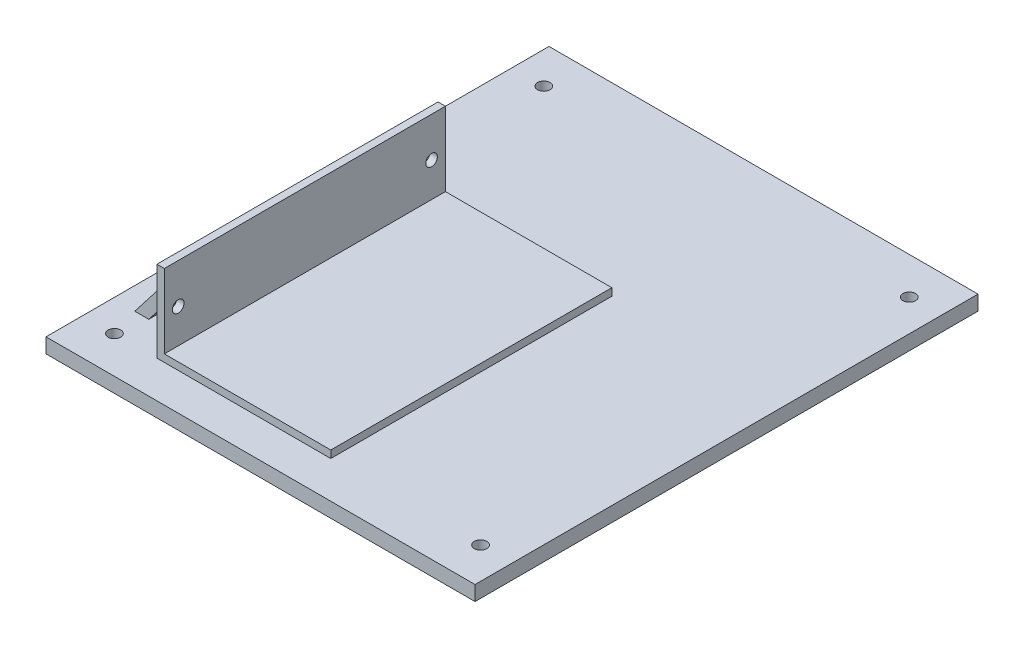
from build123d import *

# Parameters (mm, degrees)
SKETCH1_W           = 147.32
SKETCH1_H           = 5.08
BOSS_EXTRUDE1_DEPTH = 172.72
SKETCH2_R           = 2.159
CUT_EXTRUDE1_DEPTH  = 6.08
SKETCH3_W           = 59.69
SKETCH3_H           = 96.52
BOSS_EXTRUDE2_DEPTH = 2.54
SKETCH4_W           = 2.54
SKETCH4_H           = 96.52
BOSS_EXTRUDE3_DEPTH = 25.4
SKETCH5_W           = 76.2
SKETCH5_H           = 22.86
BOSS_EXTRUDE4_DEPTH = 17.78
CUT_EXTRUDE2_DEPTH  = 150.86
SKETCH7_R           = 2
CUT_EXTRUDE3_DEPTH  = 28.94


with BuildPart() as part:
    # Sketch1 → Boss-Extrude1 (new body)
    with BuildSketch(Plane.XY):
        Rectangle(SKETCH1_W, SKETCH1_H)
    extrude(amount=BOSS_EXTRUDE1_DEPTH)

    # Sketch2 → Cut-Extrude1 (cut, through all)
    with BuildSketch(Plane(origin=(0, 2.54, 0), x_dir=(1, 0, 0), z_dir=(0, 1, 0))):
        with Locations((62.738, -12.7)):
            Circle(SKETCH2_R)
        with Locations((-62.865, -160.02)):
            Circle(SKETCH2_R)
        with Locations((62.865, -160.02)):
            Circle(SKETCH2_R)
        with Locations((-62.738, -12.7)):
            Circle(SKETCH2_R)
    extrude(amount=-CUT_EXTRUDE1_DEPTH, mode=Mode.SUBTRACT)

    # Sketch3 → Boss-Extrude2 (add)
    with BuildSketch(Plane(origin=(0, 2.54, 0), x_dir=(1, 0, 0), z_dir=(0, 1, 0))):
        with Locations((-18.415, -111.76)):
            Rectangle(SKETCH3_W, SKETCH3_H)
    extrude(amount=BOSS_EXTRUDE2_DEPTH)

    # Sketch4 → Boss-Extrude3 (add)
    with BuildSketch(Plane(origin=(0, 5.08, 0), x_dir=(1, 0, 0), z_dir=(0, 1, 0))):
        with Locations((-46.99, -111.76)):
            Rectangle(SKETCH4_W, SKETCH4_H)
    extrude(amount=BOSS_EXTRUDE3_DEPTH)

    # Sketch5 → Boss-Extrude4 (add)
    with BuildSketch(Plane.ZY.offset(48.26)):
        with Locations((111.76, 13.97)):
            Rectangle(SKETCH5_W, SKETCH5_H)
    extrude(amount=BOSS_EXTRUDE4_DEPTH)

    # Sketch6 → Cut-Extrude2 (cut, through all)
    with BuildSketch(Plane.XY.offset(149.86)):
        Polygon((-66.04, 2.54), (-48.26, 25.4), (-66.04, 25.4), align=None)
        Polygon((-61.213257367, 2.54), (-48.26, 19.194188043), (-48.26, 2.54), align=None)
    extrude(amount=-CUT_EXTRUDE2_DEPTH, mode=Mode.SUBTRACT)

    # Sketch7 → Cut-Extrude3 (cut, through all)
    with BuildSketch(Plane(origin=(-45.72, 0, 0), x_dir=(0, 0, -1), z_dir=(1, 0, 0))):
        with Locations((-155.26, 16.83)):
            Circle(SKETCH7_R)
        with Locations((-68.26, 16.83)):
            Circle(SKETCH7_R)
    extrude(amount=-CUT_EXTRUDE3_DEPTH, mode=Mode.SUBTRACT)


solid = part.part
